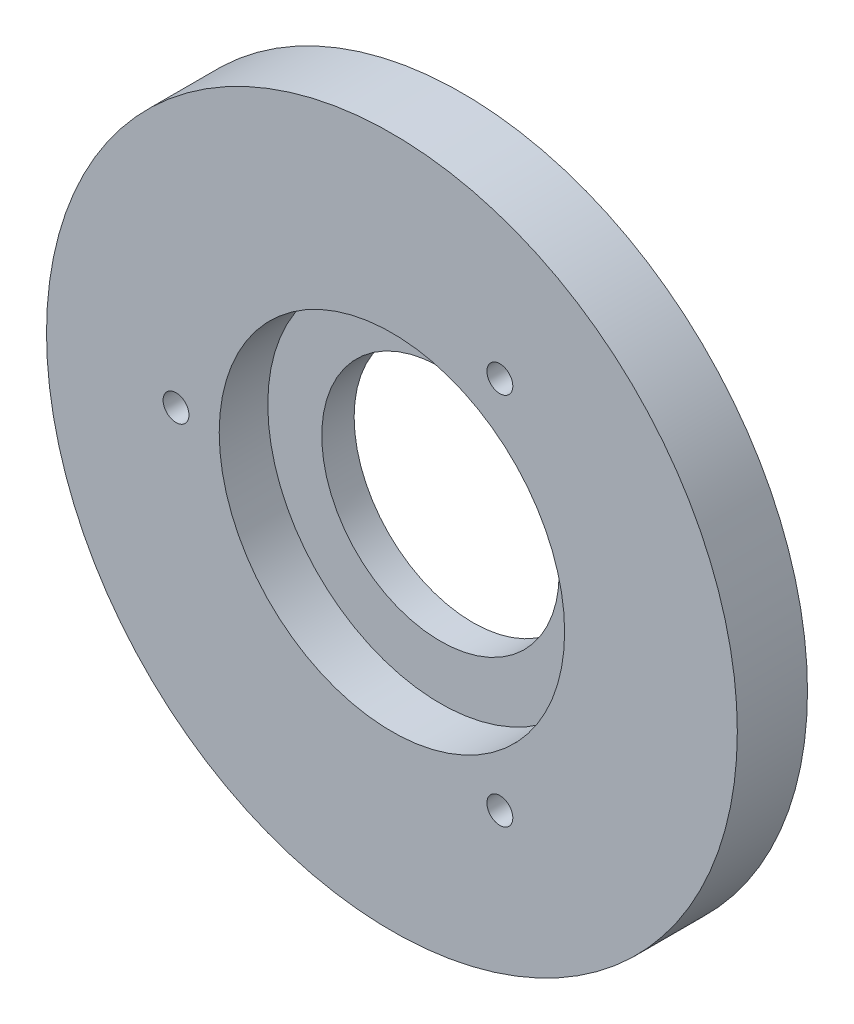
from build123d import *

# Parameters (mm, degrees)
SKETCH_1_R          = 16
EXTRUDE_1_DEPTH     = 9
SKETCH_2_R          = 6
EXTRUDE_2_DEPTH     = 0.5
SKETCH_3_R          = 16
EXTRUDE_3_DEPTH     = 3.25
SKETCH_4_R          = 5.5
EXTRUDE_4_DEPTH     = 2.25
SKETCH_5_R          = 3
CUT_EXTRUDE_1_DEPTH = 26.25
SKETCH_6_R          = 8
SKETCH_6_R_2        = 5.5
CUT_EXTRUDE_2_DEPTH = 2.25
SKETCH_7_R          = 0.6
CUT_EXTRUDE_3_DEPTH = 6
SKETCH_8_R          = 0.6
CUT_EXTRUDE_4_DEPTH = 3
SKETCH_9_R          = 28.808997231
CUT_EXTRUDE_5_DEPTH = 9
SKETCH_10_R         = 5.5
CUT_EXTRUDE_6_DEPTH = 9


with BuildPart() as part:
    # 草图1 → 凸台-拉伸1 (new body)
    with BuildSketch(Plane.XY):
        Circle(SKETCH_1_R)
    extrude(amount=EXTRUDE_1_DEPTH)

    # 草图2 → 凸台-拉伸2 (add)
    with BuildSketch(Plane.XY.offset(9)):
        Circle(SKETCH_2_R)
    extrude(amount=EXTRUDE_2_DEPTH)

    # 草图3 → 凸台-拉伸3 (add)
    with BuildSketch(Plane.XY.offset(9.5)):
        Circle(SKETCH_3_R)
    extrude(amount=EXTRUDE_3_DEPTH)

    # 草图4 → 凸台-拉伸4 (add)
    with BuildSketch(Plane.XY.offset(12.75)):
        Circle(SKETCH_4_R)
    extrude(amount=EXTRUDE_4_DEPTH)

    # 草图5 → 切除-拉伸1 (cut)
    with BuildSketch(Plane.XY.offset(15)):
        Circle(SKETCH_5_R)
    extrude(amount=-CUT_EXTRUDE_1_DEPTH, mode=Mode.SUBTRACT)

    # 草图6 → 切除-拉伸2 (cut)
    with BuildSketch(Plane.XY.offset(12.75)):
        Circle(SKETCH_6_R)
        Circle(SKETCH_6_R_2, mode=Mode.SUBTRACT)
    extrude(amount=-CUT_EXTRUDE_2_DEPTH, mode=Mode.SUBTRACT)

    # 草图7 → 切除-拉伸3 (cut)
    with BuildSketch(Plane(origin=(0, 0, 0), x_dir=(-1, 0, 0), z_dir=(0, 0, -1))):
        with Locations((8.660254038, 5)):
            Circle(SKETCH_7_R)
        with Locations((-8.660254038, 5)):
            Circle(SKETCH_7_R)
        with Locations((0, -10)):
            Circle(SKETCH_7_R)
    extrude(amount=-CUT_EXTRUDE_3_DEPTH, mode=Mode.SUBTRACT)

    # 草图8 → 切除-拉伸4 (cut)
    with BuildSketch(Plane.XY.offset(12.75)):
        with Locations((5, -8.660254038)):
            Circle(SKETCH_8_R)
        with Locations((5, 8.660254038)):
            Circle(SKETCH_8_R)
        with Locations((-10, 0)):
            Circle(SKETCH_8_R)
    extrude(amount=-CUT_EXTRUDE_4_DEPTH, mode=Mode.SUBTRACT)

    # 草图9 → 切除-拉伸5 (cut)
    with BuildSketch(Plane(origin=(0, 0, 0), x_dir=(-1, 0, 0), z_dir=(0, 0, -1))):
        Circle(SKETCH_9_R)
    extrude(amount=-CUT_EXTRUDE_5_DEPTH, mode=Mode.SUBTRACT)

    # 草图10 → 切除-拉伸6 (cut)
    with BuildSketch(Plane.XY.offset(15)):
        Circle(SKETCH_10_R)
    extrude(amount=-CUT_EXTRUDE_6_DEPTH, mode=Mode.SUBTRACT)


solid = part.part
